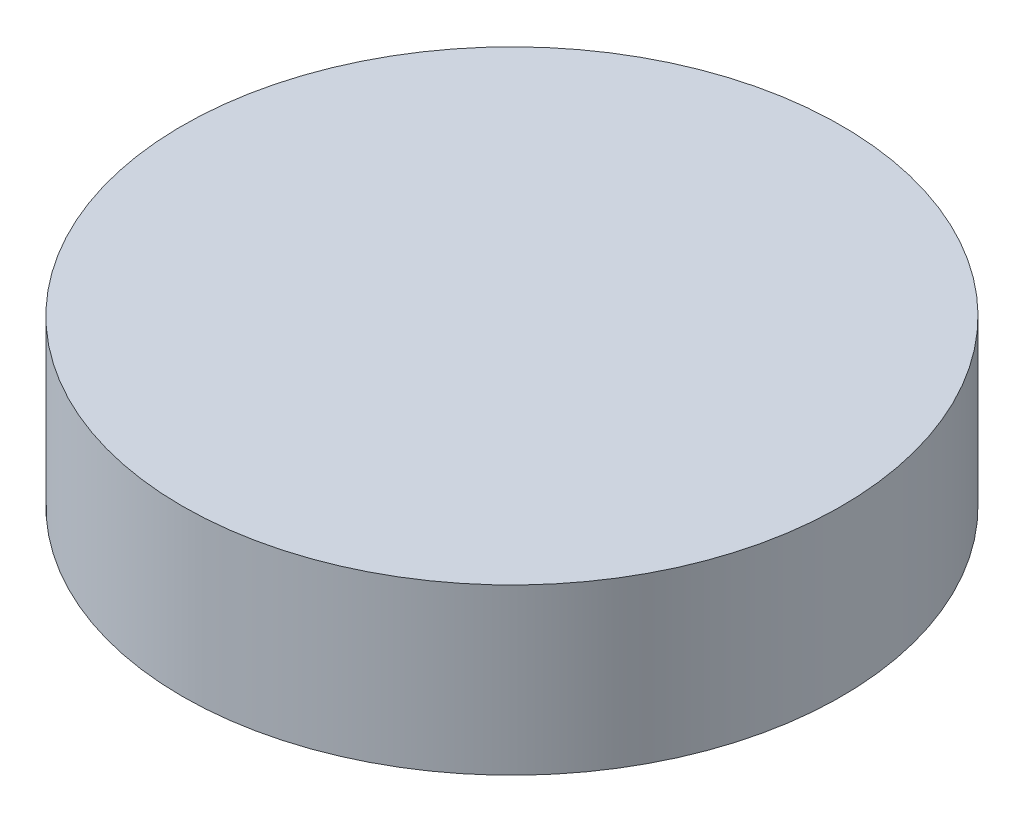
from build123d import *

# Parameters (mm, degrees)
SKETCH1_R           = 2.54
BOSS_EXTRUDE1_DEPTH = 1.27


with BuildPart() as part:
    # Sketch1 → Boss-Extrude1 (new body)
    with BuildSketch(Plane(origin=(0, 0, 0), x_dir=(1, 0, 0), z_dir=(0, 1, 0))):
        Circle(SKETCH1_R)
    extrude(amount=BOSS_EXTRUDE1_DEPTH)


solid = part.part
